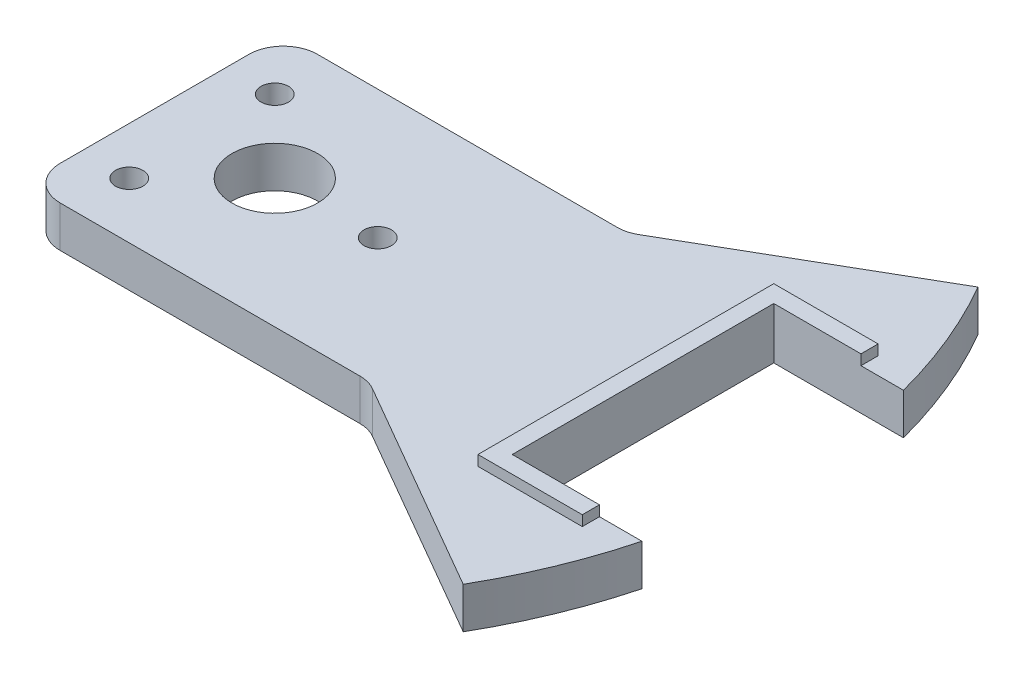
from build123d import *

# Parameters (mm, degrees)
SKETCH1_R           = 12.5
SKETCH1_R_2         = 4
BOSS_EXTRUDE1_DEPTH = 12
SKETCH3_W           = 48.002845368
SKETCH3_H           = 76.2
CUT_EXTRUDE5_DEPTH  = 13
BOSS_EXTRUDE3_DEPTH = 3


with BuildPart() as part:
    # Sketch1 → Boss-Extrude1 (new body)
    with BuildSketch(Plane(origin=(0, 0, 0), x_dir=(1, 0, 0), z_dir=(0, 1, 0))):
        with BuildLine():
            Line((67.27241336, 38.839745962), (129.903810568, 75))
            ThreePointArc((129.903810568, 75), (150, 0), (129.903810568, -75))
            Line((129.903810568, -75), (67.27241336, -38.839745962))
            ThreePointArc((67.27241336, -38.839745962), (64.860603811, -37.840741737), (62.27241336, -37.5))
            Line((62.27241336, -37.5), (-25.048094716, -37.5))
            ThreePointArc((-25.048094716, -37.5), (-32.119162528, -34.571067812), (-35.048094716, -27.5))
            Line((-35.048094716, -27.5), (-35.048094716, 27.5))
            ThreePointArc((-35.048094716, 27.5), (-32.119162528, 34.571067812), (-25.048094716, 37.5))
            Line((-25.048094716, 37.5), (62.27241336, 37.5))
            ThreePointArc((62.27241336, 37.5), (64.860603811, 37.840741737), (67.27241336, 38.839745962))
        make_face()
        Circle(SKETCH1_R, mode=Mode.SUBTRACT)
        with Locations((30, 0)):
            Circle(SKETCH1_R_2, mode=Mode.SUBTRACT)
        with Locations((-21.213203436, 21.213203436)):
            Circle(SKETCH1_R_2, mode=Mode.SUBTRACT)
        with Locations((-21.213203436, -21.213203436)):
            Circle(SKETCH1_R_2, mode=Mode.SUBTRACT)
    extrude(amount=BOSS_EXTRUDE1_DEPTH)

    # Sketch3 → Cut-Extrude5 (cut, through all)
    with BuildSketch(Plane(origin=(0, 12, 0), x_dir=(1, 0, 0), z_dir=(0, 1, 0))):
        with Locations((131.301422684, 0)):
            Rectangle(SKETCH3_W, SKETCH3_H)
    extrude(amount=-CUT_EXTRUDE5_DEPTH, mode=Mode.SUBTRACT)

    # Sketch4 → Boss-Extrude3 (add)
    with BuildSketch(Plane(origin=(0, 12, 0), x_dir=(1, 0, 0), z_dir=(0, 1, 0))):
        Polygon((107.3, -38.1), (107.3, 0), (102.3, 0), (102.3, -43.1), (107.3, -43.1), (132.7, -43.1), (132.7, -38.1), align=None)
        Polygon((107.3, 0), (107.3, 38.1), (132.7, 38.1), (132.7, 43.1), (107.3, 43.1), (102.3, 43.1), (102.3, 0), align=None)
    extrude(amount=BOSS_EXTRUDE3_DEPTH)


solid = part.part
